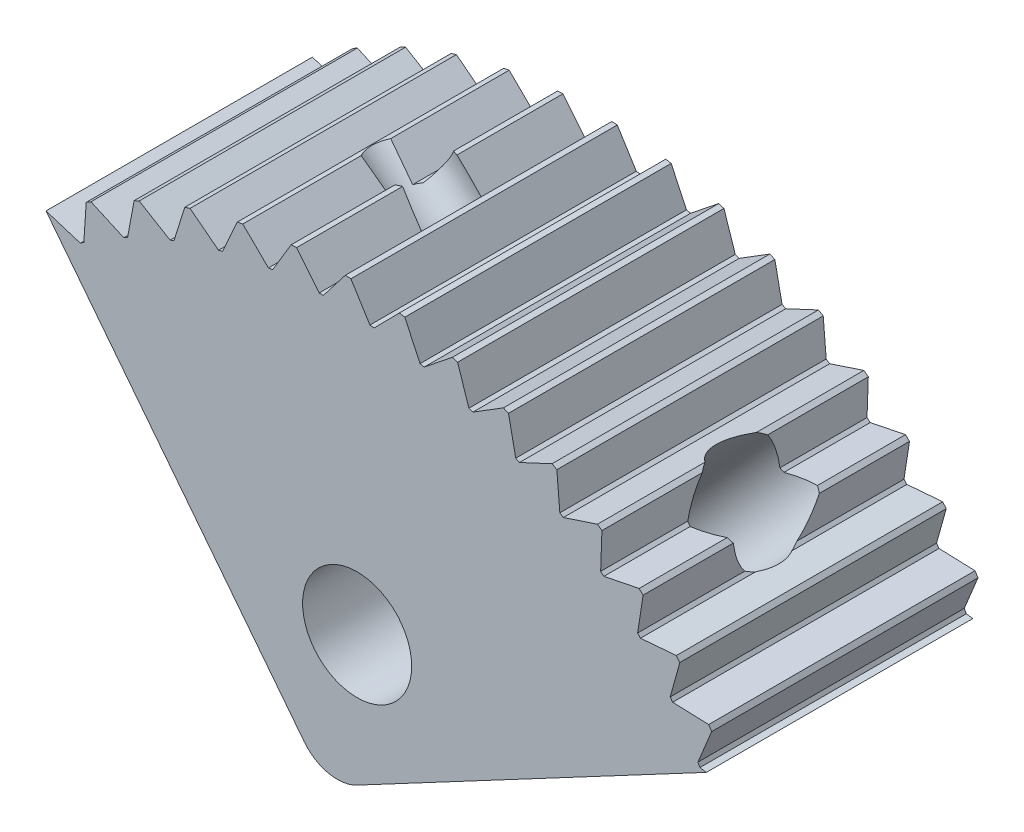
from build123d import *

# Parameters (mm, degrees)
BOSS_EXTRUDE1_DEPTH      = 3.175
BOSS_EXTRUDE1_DEPTH_BACK = 3.175
SKETCH1_R                = 1.3
SKETCH4_R                = 0.75
CUT_EXTRUDE2_DEPTH       = 6
CUT_EXTRUDE2_DEPTH_BACK  = 10
SKETCH3_R                = 1.1303
CUT_EXTRUDE3_DEPTH       = 10
CUT_EXTRUDE3_DEPTH_BACK  = 10


with BuildPart() as part:
    # Sketch1 → Boss-Extrude1 (new, two sides: drawn at the far end of the back side and taken through both)
    with BuildSketch(Plane.XY.offset(-BOSS_EXTRUDE1_DEPTH_BACK)):
        with BuildLine():
            Line((-15.888121086, 6.687358163), (-9.732209918, -1.193299023))
            ThreePointArc((-9.732209918, -1.193299023), (-9.152143222, -1.55583694), (-8.474751471, -1.460697412))
            Line((-8.474751471, -1.460697412), (0.355143581, 3.233229874))
            ThreePointArc((0.355143581, 3.233229874), (-6.971373573, 8.699375262), (-15.888121086, 6.687358163))
        make_face()
        with Locations((-8.471265065, 1.646037216)):
            Circle(SKETCH1_R, mode=Mode.SUBTRACT)
    extrude(amount=BOSS_EXTRUDE1_DEPTH + BOSS_EXTRUDE1_DEPTH_BACK)

    # Cut-Sweep1: sweep along a path in Sketch2
    with BuildLine(Plane.XY) as cut_sweep1_path:
        Line((-34.688332977, 30.754960978), (-2.463829833, 1.734677949))
    # Sketch4 → Cut-Sweep1 (sweep, cut)
    with BuildSketch(Plane(origin=(-12.934434707, -3.83144233, 0), x_dir=(0, 0, 1), z_dir=(-0.4693927285759943, 0.8829895052377368, 0))):
        with Locations((0, 11.858130603)):
            Circle(SKETCH4_R)
    sweep(path=cut_sweep1_path.line, mode=Mode.SUBTRACT)

    # Sketch3 → Cut-Extrude2 (cut, two sides: drawn at the far end of the back side and taken through both)
    with BuildSketch(Plane(origin=(2.183835725, 2.42495985, 0), x_dir=(0.743085080429895, -0.669196953999715, 0), z_dir=(-0.669196953999715, -0.743085080429895, 0)).offset(-CUT_EXTRUDE2_DEPTH_BACK)):
        with Locations((-5.633213298, 0)):
            Circle(SKETCH3_R)
    extrude(amount=CUT_EXTRUDE2_DEPTH + CUT_EXTRUDE2_DEPTH_BACK, mode=Mode.SUBTRACT)

    # Sketch5 → Cut-Extrude3 (cut, two sides: drawn at the far end of the back side and taken through both)
    with BuildSketch(Plane.XY.offset(-CUT_EXTRUDE3_DEPTH_BACK)):
        with BuildLine():
            Line((-13.944929322, 7.106889813), (-13.786557493, 7.949915507))
            ThreePointArc((-13.786557493, 7.949915507), (-14.308549845, 7.694422458), (-14.816222826, 7.411542875))
            Line((-14.816222826, 7.411542875), (-14.033546973, 7.060555032))
            Line((-14.033546973, 7.060555032), (-13.944929322, 7.106889813))
        make_face()
        with BuildLine():
            Line((-15.888121086, 6.687358163), (-15.069456424, 6.43130714))
            Line((-15.069456424, 6.43130714), (-14.98693429, 6.487788087))
            Line((-14.98693429, 6.487788087), (-14.929280724, 7.343621028))
            ThreePointArc((-14.929280724, 7.343621028), (-15.417428384, 7.028240979), (-15.888121086, 6.687358163))
        make_face()
        with BuildLine():
            Line((-12.837072778, 7.598535189), (-12.580201475, 8.416942844))
            ThreePointArc((-12.580201475, 8.416942844), (-13.128725405, 8.224916254), (-13.666266165, 8.004003048))
            Line((-13.666266165, 8.004003048), (-12.930544413, 7.562995725))
            Line((-12.930544413, 7.562995725), (-12.837072778, 7.598535189))
        make_face()
        with BuildLine():
            Line((-11.678885729, 7.955836264), (-11.327113719, 8.738159988))
            ThreePointArc((-11.327113719, 8.738159988), (-11.894484407, 8.61229015), (-12.454361999, 8.456438314))
            Line((-12.454361999, 8.456438314), (-11.77590181, 7.931590024))
            Line((-11.77590181, 7.931590024), (-11.678885729, 7.955836264))
        make_face()
        with BuildLine():
            Line((-10.486594378, 8.173787249), (-10.044849987, 8.909066686))
            ThreePointArc((-10.044849987, 8.909066686), (-10.623118568, 8.851117035), (-11.197489107, 8.762510055))
            Line((-11.197489107, 8.762510055), (-10.585795709, 8.161173923))
            Line((-10.585795709, 8.161173923), (-10.486594378, 8.173787249))
        make_face()
        with BuildLine():
            Line((-9.276902728, 8.24933465), (-8.751374796, 8.927268533))
            ThreePointArc((-8.751374796, 8.927268533), (-9.332439726, 8.938050946), (-9.91325628, 8.917930204))
            Line((-9.91325628, 8.917930204), (-9.376899498, 8.248530952))
            Line((-9.376899498, 8.248530952), (-9.276902728, 8.24933465))
        make_face()
        with BuildLine():
            Line((-8.066758561, 8.181420049), (-7.464809735, 8.792510523))
            ThreePointArc((-7.464809735, 8.792510523), (-8.040530294, 8.871873937), (-8.619655622, 8.920521326))
            Line((-8.619655622, 8.920521326), (-8.166149816, 8.192437237))
            Line((-8.166149816, 8.192437237), (-8.066758561, 8.181420049))
        make_face()
        with BuildLine():
            Line((-6.873115998, 7.970994928), (-6.203179583, 8.506680615))
            ThreePointArc((-6.203179583, 8.506680615), (-6.765489925, 8.653513149), (-7.334810479, 8.770247118))
            Line((-7.334810479, 8.770247118), (-6.970509267, 7.993678652))
            Line((-6.970509267, 7.993678652), (-6.873115998, 7.970994928))
        make_face()
        with BuildLine():
            Line((-5.712697975, 7.621007344), (-4.98415978, 8.073783287))
            ThreePointArc((-4.98415978, 8.073783287), (-5.525181936, 8.286027816), (-6.076721536, 8.469212923))
            Line((-6.076721536, 8.469212923), (-5.806728776, 7.655039805))
            Line((-5.806728776, 7.655039805), (-5.712697975, 7.621007344))
        make_face()
        with BuildLine():
            Line((-4.601761949, 7.136360623), (-3.824828795, 7.49988343))
            ThreePointArc((-3.824828795, 7.49988343), (-4.336983044, 7.774566409), (-4.863014618, 8.02163623))
            Line((-4.863014618, 8.02163623), (-4.691112911, 7.181265027))
            Line((-4.691112911, 7.181265027), (-4.601761949, 7.136360623))
        make_face()
        with BuildLine():
            Line((-3.555872135, 6.523844668), (-2.741428857, 6.793021384))
            ThreePointArc((-2.741428857, 6.793021384), (-3.217539917, 7.126294503), (-3.710693763, 7.43378759))
            Line((-3.710693763, 7.43378759), (-3.639291452, 6.578991903))
            Line((-3.639291452, 6.578991903), (-3.555872135, 6.523844668))
        make_face()
        with BuildLine():
            Line((-2.589681451, 5.792040827), (-1.749138402, 5.963100286))
            ThreePointArc((-1.749138402, 5.963100286), (-2.182535956, 6.350294389), (-2.635902987, 6.713902762))
            Line((-2.635902987, 6.713902762), (-2.666000418, 5.85665828))
            Line((-2.666000418, 5.85665828), (-2.589681451, 5.792040827))
        make_face()
        with BuildLine():
            Line((-1.716726232, 4.951201673), (-0.861859419, 5.021747332))
            ThreePointArc((-0.861859419, 5.021747332), (-1.246471568, 5.457437828), (-1.653700111, 5.872067334))
            Line((-1.653700111, 5.872067334), (-1.784875619, 5.024384055))
            Line((-1.784875619, 5.024384055), (-1.716726232, 4.951201673))
        make_face()
        with BuildLine():
            Line((-0.949236579, 4.013107365), (-0.09202269, 3.982150878))
            ThreePointArc((-0.09202269, 3.982150878), (-0.422461015, 4.460233743), (-0.777845798, 4.920075422))
            Line((-0.777845798, 4.920075422), (-1.008261615, 4.093829389))
            Line((-1.008261615, 4.093829389), (-0.949236579, 4.013107365))
        make_face()
        with BuildLine():
            Line((-0.297965025, 2.990900604), (0.549586373, 2.858875672))
            Line((0.549586373, 2.858875672), (0.355143581, 3.233229874))
            ThreePointArc((0.355143581, 3.233229874), (0.172671433, 3.555430308), (-0.020610769, 3.871264434))
            Line((-0.020610769, 3.871264434), (-0.347038768, 3.078031355))
            Line((-0.347038768, 3.078031355), (-0.297965025, 2.990900604))
        make_face()
    extrude(amount=CUT_EXTRUDE3_DEPTH + CUT_EXTRUDE3_DEPTH_BACK, mode=Mode.SUBTRACT)


solid = part.part
